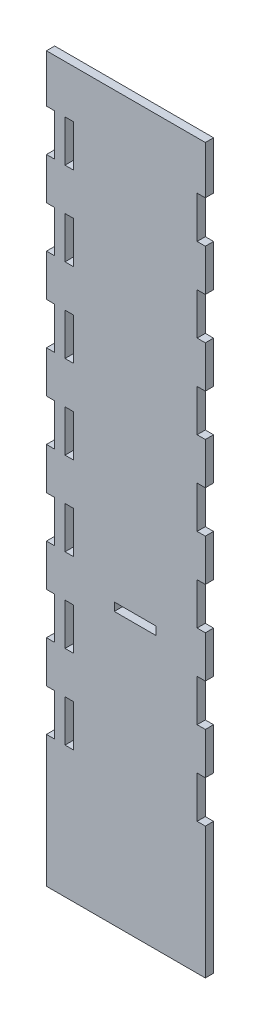
from build123d import *

# Parameters (mm, degrees)
BOSS_EXTRUDE1_DEPTH = 3.175
SKETCH3_W           = 3.175
SKETCH3_H           = 16.163636364
CUT_EXTRUDE2_DEPTH  = 10
SKETCH4_W           = 16.16
SKETCH4_H           = 3.175
CUT_EXTRUDE3_DEPTH  = 10


with BuildPart() as part:
    # Sketch1 → Boss-Extrude1 (new body)
    with BuildSketch(Plane.XY):
        Polygon((0, 50.8), (-3.175, 50.8), (-3.175, 0), (58.175, 0), (58.175, 50.8), (55, 50.8), (55, 66.963636364), (58.175, 66.963636364), (58.175, 83.12), (55, 83.12), (55, 99.283636364), (58.175, 99.283636364), (58.175, 115.44), (55, 115.44), (55, 131.603636364), (58.175, 131.603636364), (58.175, 147.76), (55, 147.76), (55, 163.923636364), (58.175, 163.923636364), (58.175, 180.08), (55, 180.08), (55, 196.243636364), (58.175, 196.243636364), (58.175, 212.4), (55, 212.4), (55, 228.563636364), (58.175, 228.563636364), (58.175, 244.72), (55, 244.72), (55, 260.883636364), (58.175, 260.883636364), (58.175, 279.4), (-3.175, 279.4), (-3.175, 260.883636364), (0, 260.883636364), (0, 244.72), (-3.175, 244.72), (-3.175, 228.563636364), (0, 228.563636364), (0, 212.4), (-3.175, 212.4), (-3.175, 196.243636364), (0, 196.243636364), (0, 180.109090909), (0, 180.08), (-3.175, 180.08), (-3.175, 163.923636364), (0, 163.923636364), (0, 147.76), (-3.175, 147.76), (-3.175, 131.603636364), (0, 131.603636364), (0, 115.44), (-3.175, 115.44), (-3.175, 99.283636364), (0, 99.283636364), (0, 83.12), (-3.175, 83.12), (-3.175, 66.963636364), (0, 66.963636364), align=None)
    extrude(amount=BOSS_EXTRUDE1_DEPTH)

    # Sketch3 → Cut-Extrude2 (cut)
    with BuildSketch(Plane.XY.offset(3.175)):
        with Locations((5.5875, 58.881818182)):
            Rectangle(SKETCH3_W, SKETCH3_H)
        with Locations((5.5875, 91.201818182)):
            Rectangle(SKETCH3_W, SKETCH3_H)
        with Locations((5.5875, 123.521818182)):
            Rectangle(SKETCH3_W, SKETCH3_H)
        with Locations((5.5875, 155.841818182)):
            Rectangle(SKETCH3_W, SKETCH3_H)
        with Locations((5.5875, 188.161818182)):
            Rectangle(SKETCH3_W, SKETCH3_H)
        with Locations((5.5875, 220.481818182)):
            Rectangle(SKETCH3_W, SKETCH3_H)
        with Locations((5.5875, 252.801818182)):
            Rectangle(SKETCH3_W, SKETCH3_H)
    extrude(amount=-CUT_EXTRUDE2_DEPTH, mode=Mode.SUBTRACT)

    # Sketch4 → Cut-Extrude3 (cut)
    with BuildSketch(Plane.XY.offset(3.175)):
        with Locations((31.0875, 106.5875)):
            Rectangle(SKETCH4_W, SKETCH4_H)
    extrude(amount=-CUT_EXTRUDE3_DEPTH, mode=Mode.SUBTRACT)


solid = part.part
